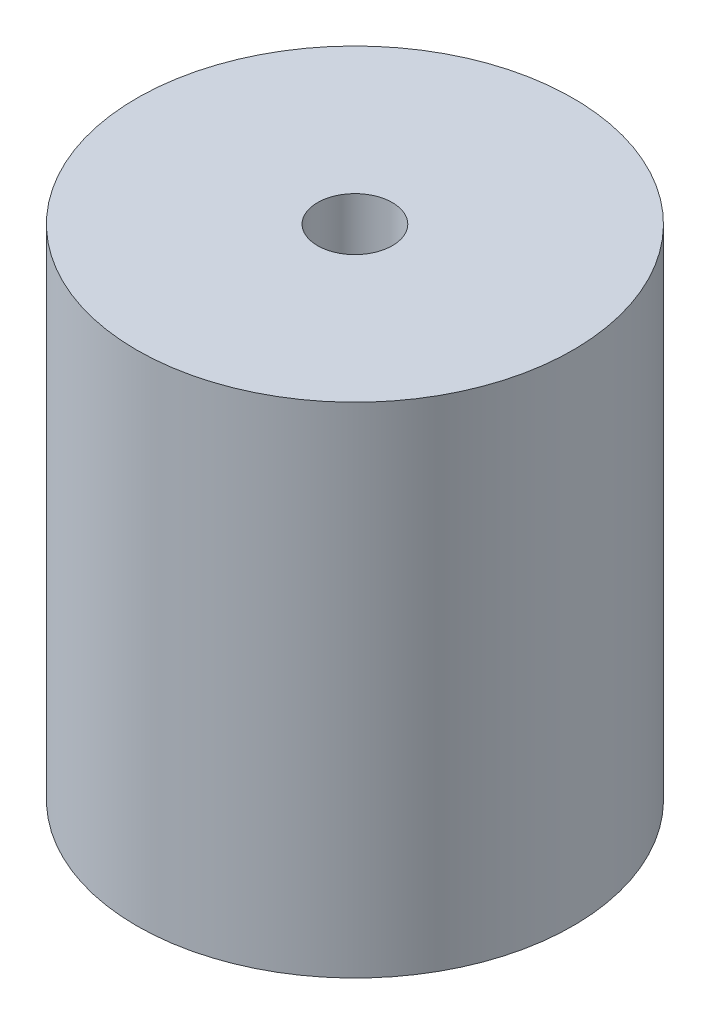
from build123d import *

# Parameters (mm, degrees)
SKETCH1_R           = 175
BOSS_EXTRUDE1_DEPTH = 400
SCALE1_SCALE        = 0.1
SKETCH3_R           = 3
CUT_EXTRUDE1_DEPTH  = 41


with BuildPart() as part:
    # Sketch1 → Boss-Extrude1 (new body)
    with BuildSketch(Plane(origin=(0, 0, 0), x_dir=(1, 0, 0), z_dir=(0, 1, 0))):
        Circle(SKETCH1_R)
    extrude(amount=BOSS_EXTRUDE1_DEPTH)


with BuildPart() as part_1:
    # Scale1: scaled about (0, 200, 0)
    add(part.part.scale(SCALE1_SCALE).moved(Location((0, 180, 0))))

    # Sketch3 → Cut-Extrude1 (cut, through all)
    with BuildSketch(Plane(origin=(0, 220, 0), x_dir=(1, 0, 0), z_dir=(0, 1, 0))):
        Circle(SKETCH3_R)
    extrude(amount=-CUT_EXTRUDE1_DEPTH, mode=Mode.SUBTRACT)


solid = part_1.part
